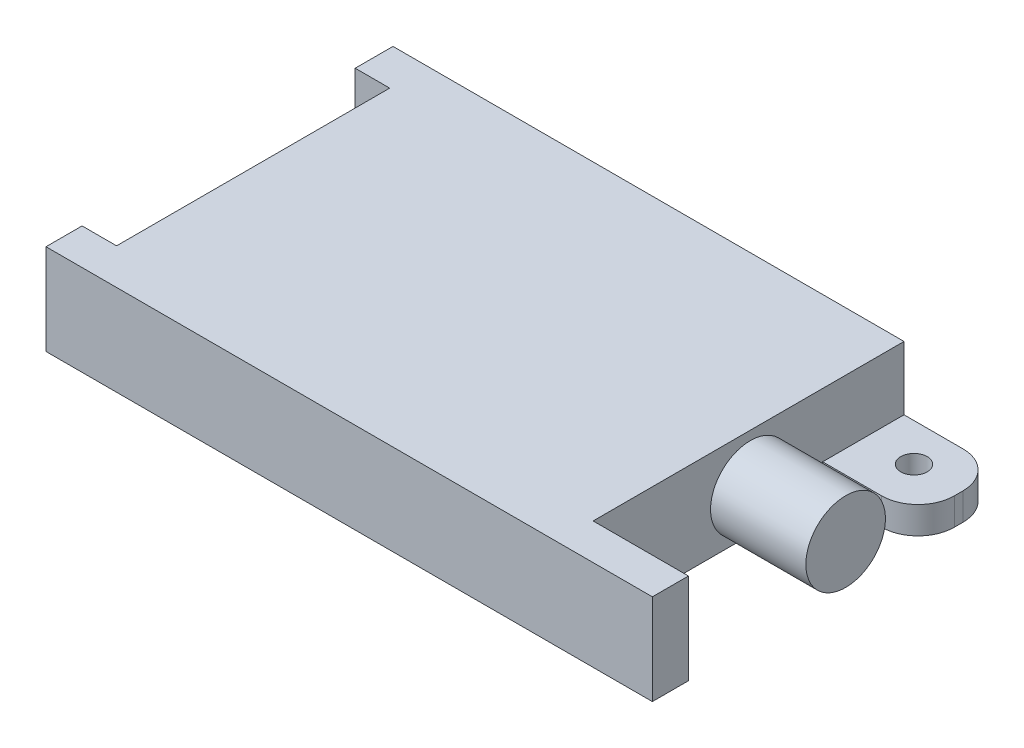
from build123d import *

# Parameters (mm, degrees)
BOSS_EXTRUDE1_DEPTH = 20
FILLET1_R           = 8
SKETCH2_W           = 25.416334399
SKETCH2_H           = 26.69942318
CUT_EXTRUDE1_DEPTH  = 14
SKETCH3_R           = 2.920242488
CUT_EXTRUDE2_DEPTH  = 7
SKETCH4_R           = 8.768125441
BOSS_EXTRUDE2_DEPTH = 21.004475


with BuildPart() as part:
    # Sketch1 → Boss-Extrude1 (new body)
    with BuildSketch(Plane(origin=(0, 0, 0), x_dir=(1, 0, 0), z_dir=(0, 1, 0))):
        Polygon((-61.131192742, -32.931354604), (72.486832261, -32.931354604), (72.486832261, -24.982406941), (51.482357687, -24.982406941), (51.482357687, 25.600715877), (72.486832261, 25.600715877), (72.486832261, 43.529951488), (-61.131192742, 43.529951488), (-61.131192742, 35.202482508), (-53.52918853, 35.202482508), (-53.52918853, -24.982406941), (-61.131192742, -24.982406941), align=None)
    extrude(amount=BOSS_EXTRUDE1_DEPTH)

    # Fillet1
    fillet1_edges = [part.edges().sort_by_distance(p)[0] for p in [
        (72.486832261, 10, -43.529951488),
        (72.486832261, 10, -25.600715877),
    ]]
    fillet(fillet1_edges, radius=FILLET1_R)

    # Sketch2 → Cut-Extrude1 (cut)
    with BuildSketch(Plane(origin=(0, 20, 0), x_dir=(1, 0, 0), z_dir=(0, 1, 0))):
        with Locations((64.190524887, 34.382431467)):
            Rectangle(SKETCH2_W, SKETCH2_H)
    extrude(amount=-CUT_EXTRUDE1_DEPTH, mode=Mode.SUBTRACT)

    # Sketch3 → Cut-Extrude2 (cut, through all)
    with BuildSketch(Plane(origin=(0, 6, 0), x_dir=(1, 0, 0), z_dir=(0, 1, 0))):
        with Locations(Location((62.010238624, 35.19513013, 0), (0, 0, 270))):  # turned: the seam where the file's is
            Circle(SKETCH3_R)
    extrude(amount=-CUT_EXTRUDE2_DEPTH, mode=Mode.SUBTRACT)

    # Sketch4 → Boss-Extrude2 (add)
    with BuildSketch(Plane(origin=(51.482357687, 0, 0), x_dir=(0, 0, -1), z_dir=(1, 0, 0))):
        with Locations(Location((9.656027264, 9.243975153, 0), (0, 0, 180))):  # turned: the seam where the file's is
            Circle(SKETCH4_R)
    extrude(amount=BOSS_EXTRUDE2_DEPTH)


solid = part.part
